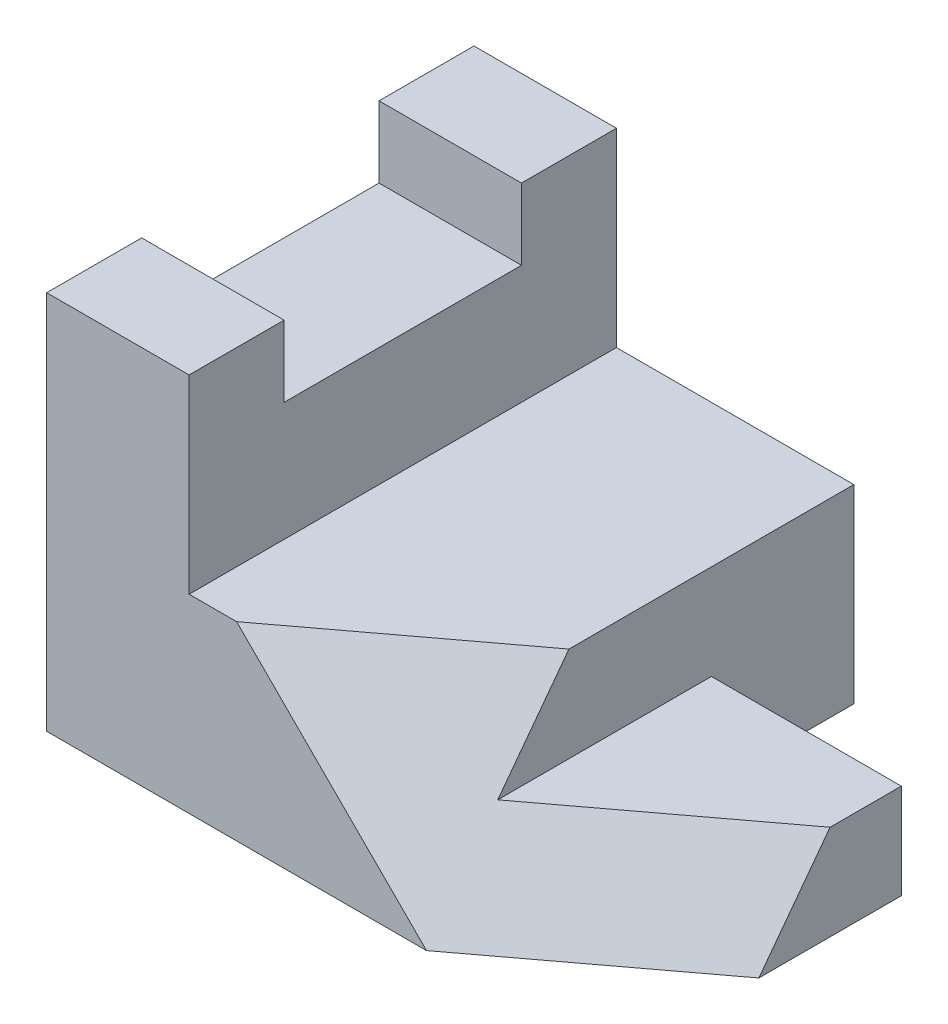
from build123d import *

# Parameters (mm, degrees)
SKETCH1_W           = 57.15
SKETCH1_H           = 25.4
BOSS_EXTRUDE1_DEPTH = 57.15
SKETCH2_W           = 25.4
SKETCH2_H           = 19.05
CUT_EXTRUDE1_DEPTH  = 85.719566807
SKETCH5_W           = 25.4
SKETCH5_H           = 12.7
CUT_EXTRUDE2_DEPTH  = 74.231772476
BOSS_EXTRUDE2_DEPTH = 19.05


with BuildPart() as part:
    # Sketch1 → Boss-Extrude1 (new body)
    with BuildSketch(Plane(origin=(0, 0, 0), x_dir=(0, 0, -1), z_dir=(1, 0, 0))):
        with Locations((-28.575, 12.7)):
            Rectangle(SKETCH1_W, SKETCH1_H)
    extrude(amount=-BOSS_EXTRUDE1_DEPTH)

    # Sketch2 → Cut-Extrude1 (cut, through all)
    with BuildSketch(Plane(origin=(0, 25.4, 0), x_dir=(1, 0, 0), z_dir=(0, 1, 0))):
        with Locations((-12.7, -9.525)):
            Rectangle(SKETCH2_W, SKETCH2_H)
    extrude(amount=-CUT_EXTRUDE1_DEPTH, mode=Mode.SUBTRACT)

    # SurfaceCut1
    split(bisect_by=Plane(origin=(13.447058824, 13.447058824, 17.929411765), x_dir=(0.8574929257125442, -0.3086974532565159, -0.41159660434202117), z_dir=(0.5144957554275265, 0.5144957554275265, 0.6859943405700355)), keep=Keep.BOTTOM)

    # Sketch5 → Cut-Extrude2 (cut, through all)
    with BuildSketch(Plane(origin=(0, 0, 19.05), x_dir=(-1, 0, 0), z_dir=(0, 0, -1))):
        with Locations((12.7, 19.05)):
            Rectangle(SKETCH5_W, SKETCH5_H)
    extrude(amount=-CUT_EXTRUDE2_DEPTH, mode=Mode.SUBTRACT)

    # Sketch6 → Boss-Extrude2 (add)
    with BuildSketch(Plane.ZY.offset(57.15)):
        Polygon((0, 0), (0, 50.8), (12.7, 50.8), (12.7, 41.275), (44.45, 41.275), (44.45, 50.8), (57.15, 50.8), (57.15, 0), align=None)
    extrude(amount=BOSS_EXTRUDE2_DEPTH)


solid = part.part
